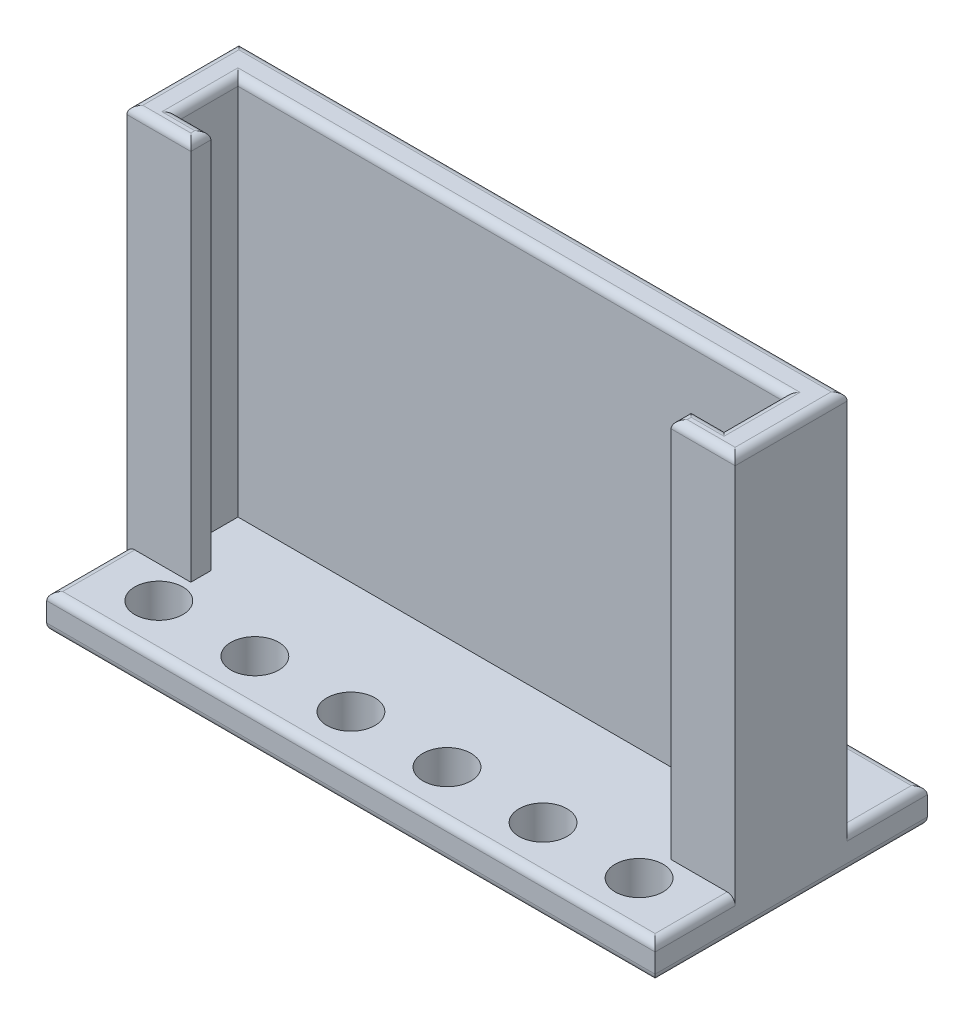
from build123d import *

# Parameters (mm, degrees)
SKETCH2_W           = 96.52
SKETCH2_H           = 66.04
BOSS_EXTRUDE1_DEPTH = 17.78
SKETCH3_W           = 96.52
SKETCH3_H           = 5.588
BOSS_EXTRUDE2_DEPTH = 12.7
SKETCH4_W           = 86.6394
SKETCH4_H           = 9.525
SKETCH4_W_2         = 76.2
SKETCH4_H_2         = 3.175
CUT_EXTRUDE1_DEPTH  = 60.452
SKETCH5_W           = 96.52
SKETCH5_H           = 5.588
BOSS_EXTRUDE3_DEPTH = 12.7
SKETCH6_R           = 2.413
SKETCH6_R_2         = 3.81
CUT_EXTRUDE2_DEPTH  = 6.588
FILLET1_R           = 1.27
FILLET2_R           = 1.27
FILLET3_R           = 1.27


with BuildPart() as part:
    # Sketch2 → Boss-Extrude1 (new body)
    with BuildSketch(Plane.XY):
        with Locations((48.26, 33.02)):
            Rectangle(SKETCH2_W, SKETCH2_H)
    extrude(amount=BOSS_EXTRUDE1_DEPTH)

    # Sketch3 → Boss-Extrude2 (add)
    with BuildSketch(Plane.XY.offset(17.78)):
        with Locations((48.26, 2.794)):
            Rectangle(SKETCH3_W, SKETCH3_H)
    extrude(amount=BOSS_EXTRUDE2_DEPTH)

    # Sketch4 → Cut-Extrude1 (cut)
    with BuildSketch(Plane(origin=(0, 66.04, 0), x_dir=(1, 0, 0), z_dir=(0, 1, 0))):
        with Locations((48.26, -9.8425)):
            Rectangle(SKETCH4_W, SKETCH4_H)
        with Locations((48.26, -16.1925)):
            Rectangle(SKETCH4_W_2, SKETCH4_H_2)
    extrude(amount=-CUT_EXTRUDE1_DEPTH, mode=Mode.SUBTRACT)

    # Sketch5 → Boss-Extrude3 (add)
    with BuildSketch(Plane(origin=(0, 0, 0), x_dir=(-1, 0, 0), z_dir=(0, 0, -1))):
        with Locations((-48.26, 2.794)):
            Rectangle(SKETCH5_W, SKETCH5_H)
    extrude(amount=BOSS_EXTRUDE3_DEPTH)

    # Sketch6 → Cut-Extrude2 (cut, through all)
    with BuildSketch(Plane(origin=(0, 5.588, 0), x_dir=(1, 0, 0), z_dir=(0, 1, 0))):
        with Locations((10.16, 6.35)):
            Circle(SKETCH6_R)
        with Locations((22.86, 6.35)):
            Circle(SKETCH6_R)
        with Locations((35.56, 6.35)):
            Circle(SKETCH6_R)
        with Locations((48.26, 6.35)):
            Circle(SKETCH6_R)
        with Locations((60.96, 6.35)):
            Circle(SKETCH6_R)
        with Locations((73.66, 6.35)):
            Circle(SKETCH6_R)
        with Locations((86.36, 6.35)):
            Circle(SKETCH6_R)
        with Locations((10.16, -22.86)):
            Circle(SKETCH6_R_2)
        with Locations((25.4, -22.86)):
            Circle(SKETCH6_R_2)
        with Locations((40.64, -22.86)):
            Circle(SKETCH6_R_2)
        with Locations((55.88, -22.86)):
            Circle(SKETCH6_R_2)
        with Locations((71.12, -22.86)):
            Circle(SKETCH6_R_2)
        with Locations((86.36, -22.86)):
            Circle(SKETCH6_R_2)
    extrude(amount=-CUT_EXTRUDE2_DEPTH, mode=Mode.SUBTRACT)

    # Fillet1
    fillet1_edges = [part.edges().sort_by_distance(p)[0] for p in [
        (91.44, 66.04, 17.78),
        (5.08, 66.04, 17.78),
        (91.5797, 66.04, 9.8425),
        (48.26, 66.04, 5.08),
        (4.9403, 66.04, 9.8425),
        (7.55015, 66.04, 14.605),
        (10.16, 66.04, 16.1925),
        (88.96985, 66.04, 14.605),
        (86.36, 66.04, 16.1925),
        (48.26, 66.04, 0),
        (0, 66.04, 8.89),
        (96.52, 66.04, 8.89),
    ]]
    fillet(fillet1_edges, radius=FILLET1_R)

    # Fillet2
    fillet2_edges = [part.edges().sort_by_distance(p)[0] for p in [
        (0, 5.588, 24.13),
        (96.52, 5.588, 24.13),
        (48.26, 5.588, 30.48),
        (96.52, 5.588, -6.35),
        (0, 5.588, -6.35),
        (48.26, 5.588, -12.7),
    ]]
    fillet(fillet2_edges, radius=FILLET2_R)

    # Fillet3
    fillet3_edges = [part.edges().sort_by_distance(p)[0] for p in [
        (48.26, 0, 30.48),
        (48.26, 0, -12.7),
        (96.52, 0, 8.89),
        (0, 0, 8.89),
    ]]
    fillet(fillet3_edges, radius=FILLET3_R)


solid = part.part
